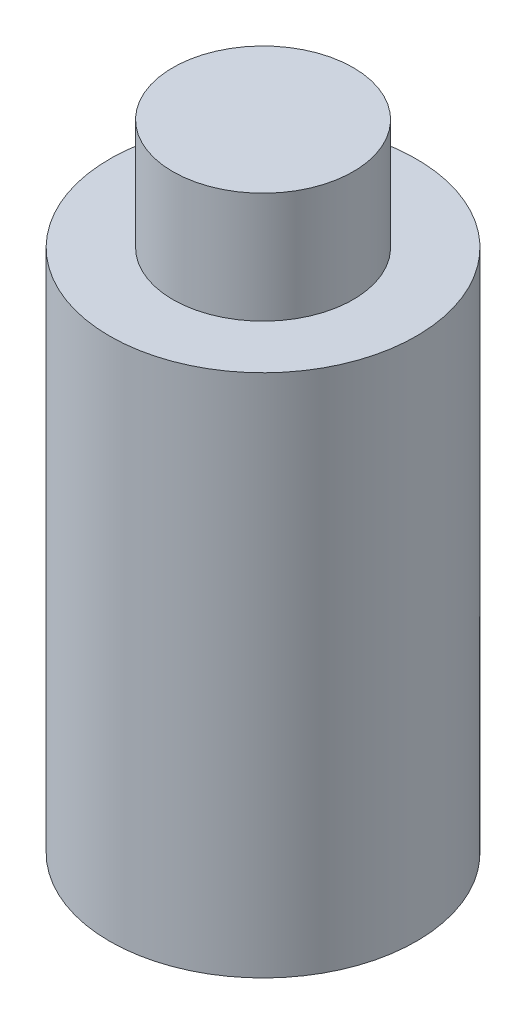
from build123d import *

# Parameters (mm, degrees)
SKETCH1_R           = 27
BOSS_EXTRUDE1_DEPTH = 92.25
SKETCH2_R           = 15.875
BOSS_EXTRUDE2_DEPTH = 19.5


with BuildPart() as part:
    # Sketch1 → Boss-Extrude1 (new body)
    with BuildSketch(Plane(origin=(0, 0, 0), x_dir=(1, 0, 0), z_dir=(0, 1, 0))):
        Circle(SKETCH1_R)
    extrude(amount=BOSS_EXTRUDE1_DEPTH)

    # Sketch2 → Boss-Extrude2 (add)
    with BuildSketch(Plane(origin=(0, 92.25, 0), x_dir=(1, 0, 0), z_dir=(0, 1, 0))):
        Circle(SKETCH2_R)
    extrude(amount=BOSS_EXTRUDE2_DEPTH)


solid = part.part
